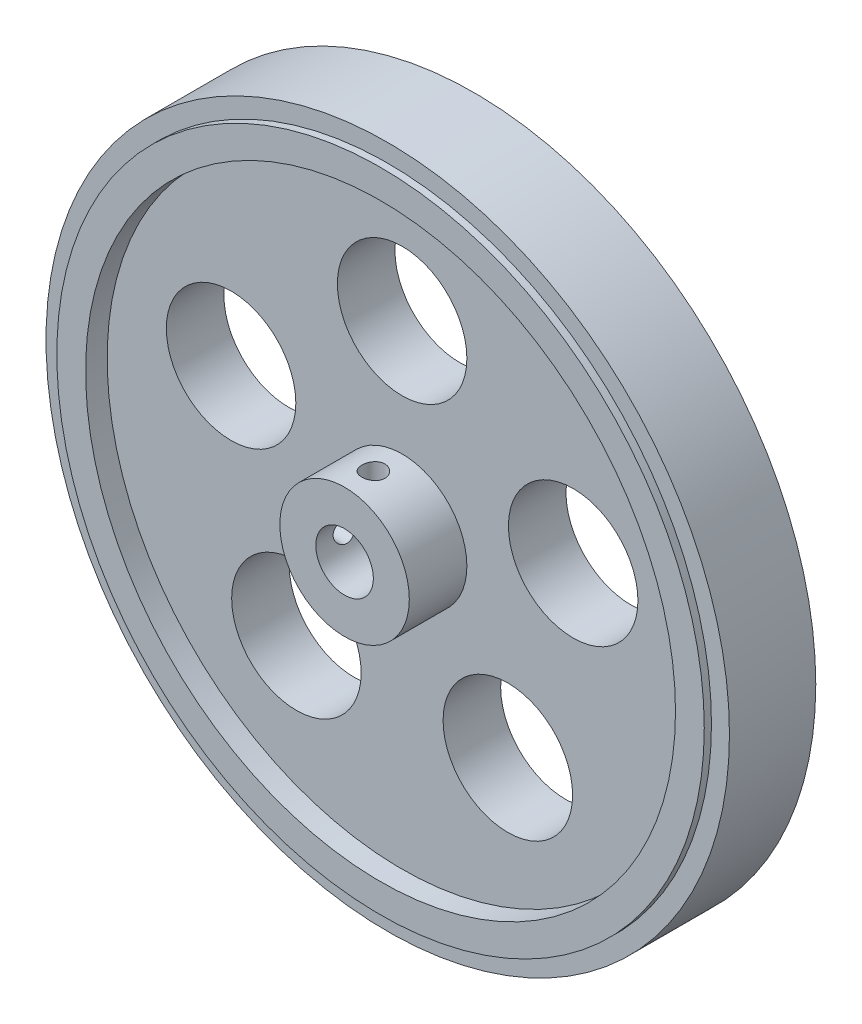
from build123d import *

# Parameters (mm, degrees)
BOSS_EXTRUDE1_DEPTH      = 6
BOSS_EXTRUDE1_DEPTH_BACK = 6
SKETCH1_R                = 47.5
SKETCH2_R                = 45
BOSS_EXTRUDE2_DEPTH      = 1
BOSS_EXTRUDE3_START      = 1
SKETCH3_R                = 45
BOSS_EXTRUDE3_DEPTH      = 1
SKETCH4_R                = 9
BOSS_EXTRUDE4_DEPTH      = 0.2
BOSS_EXTRUDE5_START      = 5
SKETCH5_R                = 9
BOSS_EXTRUDE5_DEPTH      = 5
SKETCH6_R                = 41
SKETCH6_R_2              = 9
CUT_EXTRUDE1_DEPTH       = 3
CUT_EXTRUDE2_START       = -3
SKETCH7_R                = 41
SKETCH7_R_2              = 9
CUT_EXTRUDE2_DEPTH       = 3
SKETCH8_R                = 9
CUT_EXTRUDE3_DEPTH       = 70.054326439
SKETCH9_R                = 4
CUT_EXTRUDE4_DEPTH       = 70.865155836
CUT_EXTRUDE5_REACH       = 76.783
SKETCH10_R               = 1.6
CUT_EXTRUDE6_REACH       = 76.783
SKETCH11_R               = 1.6


with BuildPart() as part:
    # Sketch1 → Boss-Extrude1 (new, two sides: drawn at the far end of the back side and taken through both)
    with BuildSketch(Plane.XY.offset(-BOSS_EXTRUDE1_DEPTH_BACK)):
        Circle(SKETCH1_R)
    extrude(amount=BOSS_EXTRUDE1_DEPTH + BOSS_EXTRUDE1_DEPTH_BACK)

    # Sketch2 → Boss-Extrude2 (add)
    with BuildSketch(Plane.XY.offset(6)):
        Circle(SKETCH2_R)
    extrude(amount=BOSS_EXTRUDE2_DEPTH)

    # Sketch3 → Boss-Extrude3 (add)
    with BuildSketch(Plane(origin=(0, 0, -6), x_dir=(-1, 0, 0), z_dir=(0, 0, -1)).offset(BOSS_EXTRUDE3_START)):
        Circle(SKETCH3_R)
    extrude(amount=-BOSS_EXTRUDE3_DEPTH)

    # Sketch4 → Boss-Extrude4 (add)
    with BuildSketch(Plane(origin=(0, 0, -7), x_dir=(-1, 0, 0), z_dir=(0, 0, -1))):
        Circle(SKETCH4_R)
    extrude(amount=BOSS_EXTRUDE4_DEPTH)

    # Sketch5 → Boss-Extrude5 (add)
    with BuildSketch(Plane.XY.offset(7).offset(BOSS_EXTRUDE5_START)):
        Circle(SKETCH5_R)
    extrude(amount=-BOSS_EXTRUDE5_DEPTH)

    # Sketch6 → Cut-Extrude1 (cut)
    with BuildSketch(Plane.XY.offset(7)):
        Circle(SKETCH6_R)
        Circle(SKETCH6_R_2, mode=Mode.SUBTRACT)
    extrude(amount=-CUT_EXTRUDE1_DEPTH, mode=Mode.SUBTRACT)

    # Sketch7 → Cut-Extrude2 (cut)
    with BuildSketch(Plane(origin=(0, 0, -7), x_dir=(-1, 0, 0), z_dir=(0, 0, -1)).offset(CUT_EXTRUDE2_START)):
        Circle(SKETCH7_R)
        Circle(SKETCH7_R_2, mode=Mode.SUBTRACT)
    extrude(amount=CUT_EXTRUDE2_DEPTH, mode=Mode.SUBTRACT)

    # Sketch8 → Cut-Extrude3 (cut, through all)
    with BuildSketch(Plane(origin=(0, 0, -4), x_dir=(-1, 0, 0), z_dir=(0, 0, -1))):
        with Locations((0, 25)):
            Circle(SKETCH8_R)
        with Locations((23.776412907, 7.725424859)):
            Circle(SKETCH8_R)
        with Locations((14.694631307, -20.225424859)):
            Circle(SKETCH8_R)
        with Locations((-14.694631307, -20.225424859)):
            Circle(SKETCH8_R)
        with Locations((-23.776412907, 7.725424859)):
            Circle(SKETCH8_R)
    extrude(amount=-CUT_EXTRUDE3_DEPTH, mode=Mode.SUBTRACT)

    # Sketch9 → Cut-Extrude4 (cut, through all)
    with BuildSketch(Plane.XY.offset(12)):
        Circle(SKETCH9_R)
    extrude(amount=-CUT_EXTRUDE4_DEPTH, mode=Mode.SUBTRACT)

    # Sketch10 → Cut-Extrude5 (cut, up to next)
    with BuildSketch(Plane.ZY.offset(9), mode=Mode.PRIVATE) as cut_extrude5_sk1:
        with Locations((8, 0)):
            Circle(SKETCH10_R)
    cut_extrude5_tool1 = extrude(cut_extrude5_sk1.sketch, amount=-CUT_EXTRUDE5_REACH, mode=Mode.PRIVATE) & part.part
    add(cut_extrude5_tool1.solids().sort_by_distance((-9, 0, 8))[0], mode=Mode.SUBTRACT)

    # Sketch11 → Cut-Extrude6 (cut, up to next)
    with BuildSketch(Plane(origin=(0, 9, 0), x_dir=(1, 0, 0), z_dir=(0, 1, 0)), mode=Mode.PRIVATE) as cut_extrude6_sk1:
        with Locations((0, -8)):
            Circle(SKETCH11_R)
    cut_extrude6_tool1 = extrude(cut_extrude6_sk1.sketch, amount=-CUT_EXTRUDE6_REACH, mode=Mode.PRIVATE) & part.part
    add(cut_extrude6_tool1.solids().sort_by_distance((0, 9, 8))[0], mode=Mode.SUBTRACT)


solid = part.part
